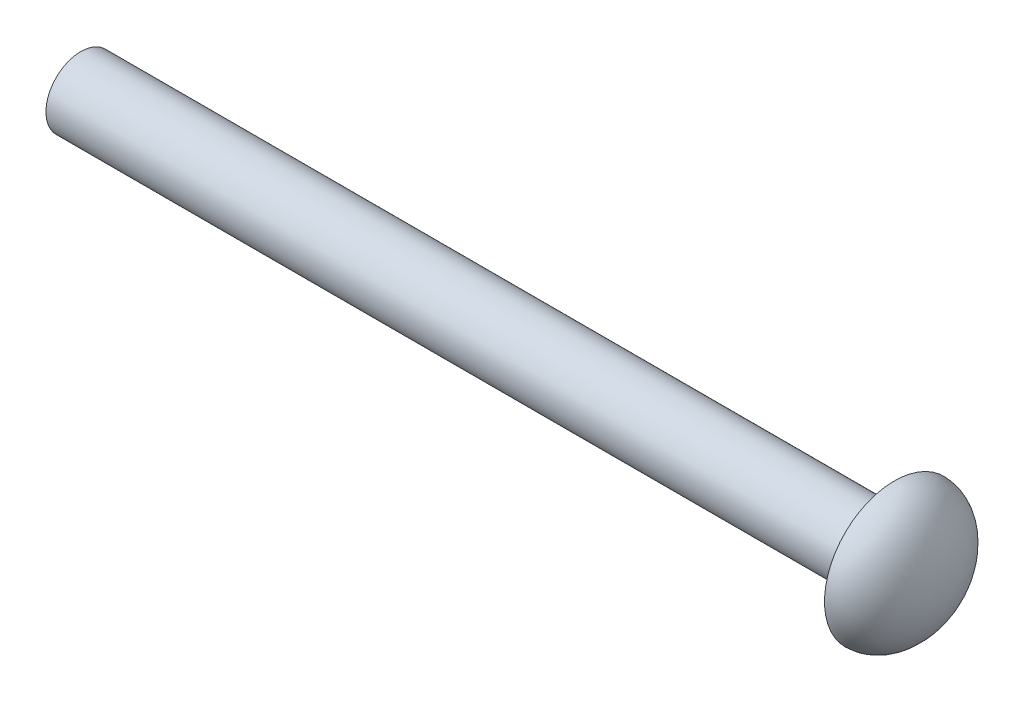
from build123d import *

# Parameters (mm, degrees)
SKETCH1_R           = 1.5
BOSS_EXTRUDE1_DEPTH = 35


with BuildPart() as part:
    # Sketch1 → Boss-Extrude1 (new body)
    with BuildSketch(Plane(origin=(0, 0, 0), x_dir=(0, 0, -1), z_dir=(1, 0, 0))):
        Circle(SKETCH1_R)
    extrude(amount=BOSS_EXTRUDE1_DEPTH)

    # Sketch2 → Revolve1 (revolve)
    with BuildSketch(Plane(origin=(0, 0, 0), x_dir=(1, 0, 0), z_dir=(0, 1, 0))):
        with BuildLine():
            Line((35, 0), (35, 3))
            add(Edge.make_bspline(
                [(37, 0), (37, 3), (35, 3)],
                knots=[4.71238898, 4.71238898, 4.71238898, 6.283185307, 6.283185307, 6.283185307], degree=2, weights=[1, 0.707106781, 1]))
            Line((37, 0), (35, 0))
        make_face()
    revolve(axis=Axis((37, 0, 0), (-1, 0, 0)))


solid = part.part
